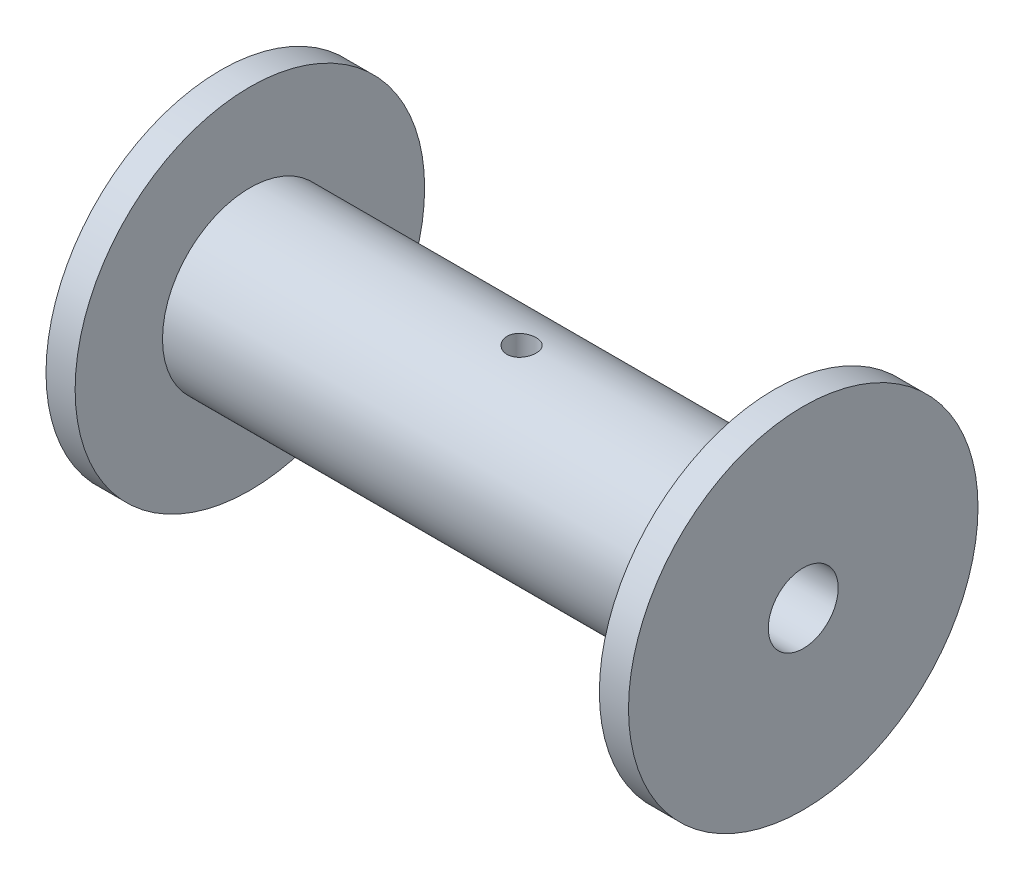
from build123d import *

# Parameters (mm, degrees)
SKETCH1_R               = 19.05
BOSS_EXTRUDE1_DEPTH     = 3.175
SKETCH2_R               = 9.525
BOSS_EXTRUDE2_DEPTH     = 57.15
SKETCH3_R               = 19.05
BOSS_EXTRUDE3_DEPTH     = 3.175
SKETCH4_R               = 3.81
CUT_EXTRUDE1_DEPTH      = 63.5
CUT_EXTRUDE2_REACH      = 30.575
CUT_EXTRUDE2_END_RADIUS = 3.81
SKETCH5_R               = 1.5
SKETCH6_R               = 1.5875
CUT_EXTRUDE3_DEPTH      = 20.05
CUT_EXTRUDE3_DEPTH_BACK = 20.05


with BuildPart() as part:
    # Sketch1 → Boss-Extrude1 (new body)
    with BuildSketch(Plane(origin=(0, 0, 0), x_dir=(0, 0, -1), z_dir=(1, 0, 0))):
        Circle(SKETCH1_R)
    extrude(amount=BOSS_EXTRUDE1_DEPTH)

    # Sketch2 → Boss-Extrude2 (add)
    with BuildSketch(Plane(origin=(3.175, 0, 0), x_dir=(0, 0, -1), z_dir=(1, 0, 0))):
        Circle(SKETCH2_R)
    extrude(amount=BOSS_EXTRUDE2_DEPTH)

    # Sketch3 → Boss-Extrude3 (add)
    with BuildSketch(Plane(origin=(60.325, 0, 0), x_dir=(0, 0, -1), z_dir=(1, 0, 0))):
        Circle(SKETCH3_R)
    extrude(amount=BOSS_EXTRUDE3_DEPTH)

    # Sketch4 → Cut-Extrude1 (cut)
    with BuildSketch(Plane(origin=(63.5, 0, 0), x_dir=(0, 0, -1), z_dir=(1, 0, 0))):
        Circle(SKETCH4_R)
    extrude(amount=-CUT_EXTRUDE1_DEPTH, mode=Mode.SUBTRACT)

    # Cut-Extrude2: up to this cylinder (the profile starts outside it)
    cut_extrude2_end = Plane(origin=(8.630484, 0, 0), z_dir=(1, 0, 0)) * Cylinder(CUT_EXTRUDE2_END_RADIUS, 69.77, mode=Mode.PRIVATE)
    # Sketch5 → Cut-Extrude2 (cut, up to the surface)
    with BuildSketch(Plane(origin=(0, 0, -9.525), x_dir=(-1, 0, 0), z_dir=(0, 0, -1)), mode=Mode.PRIVATE) as cut_extrude2_sk1:
        with Locations((-8.630483707, 0)):
            Circle(SKETCH5_R)
    cut_extrude2_tool1 = extrude(cut_extrude2_sk1.sketch, amount=-CUT_EXTRUDE2_REACH, mode=Mode.PRIVATE) - cut_extrude2_end
    add(cut_extrude2_tool1.solids().sort_by_distance((8.630484, 0, -9.525))[0], mode=Mode.SUBTRACT)

    # Sketch6 → Cut-Extrude3 (cut, two sides)
    with BuildSketch(Plane(origin=(0, 0, 0), x_dir=(1, 0, 0), z_dir=(0, 1, 0))) as cut_extrude3_sk:
        with Locations(Location((32.798989334, 0, 0), (0, 0, 270))):  # turned: the seam where the file's is
            Circle(SKETCH6_R)
    extrude(amount=CUT_EXTRUDE3_DEPTH, mode=Mode.SUBTRACT)
    extrude(cut_extrude3_sk.sketch, amount=-CUT_EXTRUDE3_DEPTH_BACK, mode=Mode.SUBTRACT)


solid = part.part
